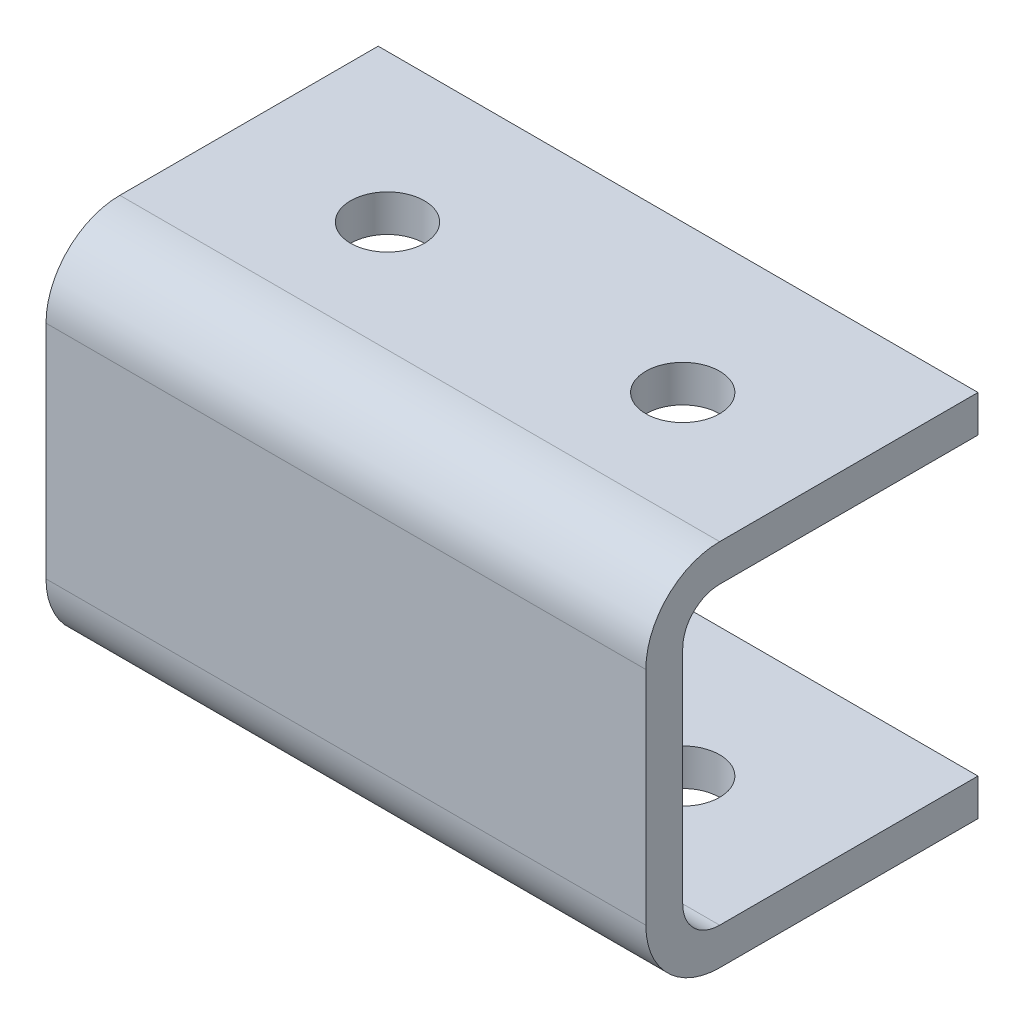
from build123d import *

# Parameters (mm, degrees)
SKETCH1_W          = 889
SKETCH1_H          = 31.75
EXTRUDE1_DEPTH     = 28.575
EXTRUDE2_REACH     = 891.702
SKETCH2_W          = 25.4
SKETCH2_H          = 25.4
HOLE1_D            = 6.35
HOLE1_DEPTH        = 3.175
LPATTERN1_COUNT    = 35
LPATTERN1_PITCH    = 25.4
HOLE2_D            = 9.652
LPATTERN2_COUNT    = 12
LPATTERN2_PITCH    = 25.4
HOLE3_D            = 9.652
HOLE4_D            = 9.652
LPATTERN3_COUNT    = 12
LPATTERN3_PITCH    = 25.4
HOLE5_D            = 3.175
HOLE6_D            = 6.35
LPATTERN4_COUNT    = 35
LPATTERN4_PITCH    = 25.4
FILLET1_R          = 3.175
FILLET2_R          = 3.175
FILLET3_R          = 6.35
FILLET4_R          = 6.35
SKETCH16_W         = 145.760071232
SKETCH16_H         = 71.504803879
CUT_EXTRUDE2_DEPTH = 75
SKETCH17_W         = 473.628565651
SKETCH17_H         = 66.908943447
CUT_EXTRUDE3_DEPTH = 186
SKETCH18_W         = 383.094897193
SKETCH18_H         = 93.915816603
CUT_EXTRUDE4_DEPTH = 186
SKETCH19_W         = 44.323760151
SKETCH19_H         = 53.749642994
CUT_EXTRUDE5_DEPTH = 186


with BuildPart() as part:
    # Sketch1 → Extrude1 (new body)
    with BuildSketch(Plane.XY.offset(3.175)):
        with Locations((428.480011997, 8.672957166)):
            Rectangle(SKETCH1_W, SKETCH1_H)
    extrude(amount=-EXTRUDE1_DEPTH)

    # Sketch2 → Extrude2 (cut, up to next)
    with BuildSketch(Plane.ZY.offset(16.019988003), mode=Mode.PRIVATE) as extrude2_sk1:
        with Locations((-12.7, 8.672957166)):
            Rectangle(SKETCH2_W, SKETCH2_H)
    extrude2_tool1 = extrude(extrude2_sk1.sketch, amount=-EXTRUDE2_REACH, mode=Mode.PRIVATE) & part.part
    add(extrude2_tool1.solids().sort_by_distance((-16.019988, 8.672957, -12.7))[0], mode=Mode.SUBTRACT)

    # Hole1
    with Locations(Plane(origin=(0, 24.547957166, 0), x_dir=(-1, 0, 0), z_dir=(0, 1, 0))):
        with Locations((3.319988003, -12.7)):
            hole1 = Hole(HOLE1_D / 2, depth=HOLE1_DEPTH)

    # LPattern1: Hole1 ×35
    with Locations(*[(i * LPATTERN1_PITCH, 0, 0) for i in range(1, LPATTERN1_COUNT)]):
        add(hole1, mode=Mode.SUBTRACT)

    # Hole2 (through all)
    with Locations(Plane.XY.offset(3.175)):
        with Locations((66.530011997, 10.577957166)):
            hole2 = Hole(HOLE2_D / 2)

    # LPattern2: Hole2 ×12, 8 skipped
    with Locations(*[(i * LPATTERN2_PITCH, 0, 0) for i in range(1, LPATTERN2_COUNT) if i not in (2, 3, 4, 5, 6, 7, 8, 9)]):
        add(hole2, mode=Mode.SUBTRACT)

    # Hole3 (through all)
    with Locations(Plane.XY.offset(3.175)):
        with Locations((428.480011997, 6.767957166)):
            Hole(HOLE3_D / 2)

    # Hole4 (through all)
    with Locations(Plane.XY.offset(3.175)):
        with Locations((511.030011997, 10.577957166)):
            hole4 = Hole(HOLE4_D / 2)

    # LPattern3: Hole4 ×12, 8 skipped
    with Locations(*[(i * LPATTERN3_PITCH, 0, 0) for i in range(1, LPATTERN3_COUNT) if i not in (2, 3, 4, 5, 6, 7, 8, 9)]):
        add(hole4, mode=Mode.SUBTRACT)

    # Hole5 (through all)
    with Locations(Plane.XY.offset(3.175)):
        with Locations((669.780011997, 8.672957166)):
            Hole(HOLE5_D / 2)

    # Hole6 (through all)
    with Locations(Plane(origin=(0, -4.027042834, 0), x_dir=(-1, 0, 0), z_dir=(0, 1, 0))):
        with Locations((3.319988003, -12.7)):
            hole6 = Hole(HOLE6_D / 2)

    # LPattern4: Hole6 ×35
    with Locations(*[(i * LPATTERN4_PITCH, 0, 0) for i in range(1, LPATTERN4_COUNT)]):
        add(hole6, mode=Mode.SUBTRACT)

    # Fillet1
    fillet1_edges = [part.edges().sort_by_distance(p)[0] for p in [
        (428.480011997, 21.372957166, 0),
    ]]
    fillet(fillet1_edges, radius=FILLET1_R)

    # Fillet2
    fillet2_edges = [part.edges().sort_by_distance(p)[0] for p in [
        (428.480011997, -4.027042834, 0),
    ]]
    fillet(fillet2_edges, radius=FILLET2_R)

    # Fillet3
    fillet3_edges = [part.edges().sort_by_distance(p)[0] for p in [
        (428.480011997, -7.202042834, 3.175),
    ]]
    fillet(fillet3_edges, radius=FILLET3_R)

    # Fillet4
    fillet4_edges = [part.edges().sort_by_distance(p)[0] for p in [
        (428.480011997, 24.547957166, 3.175),
    ]]
    fillet(fillet4_edges, radius=FILLET4_R)

    # Sketch16 → Cut-Extrude2 (cut)
    with BuildSketch(Plane(origin=(0, 24.547957166, 0), x_dir=(1, 0, 0), z_dir=(0, 1, 0))):
        with Locations((40.099976381, -10.352401939)):
            Rectangle(SKETCH16_W, SKETCH16_H)
    extrude(amount=-CUT_EXTRUDE2_DEPTH, mode=Mode.SUBTRACT)

    # Sketch17 → Cut-Extrude3 (cut)
    with BuildSketch(Plane(origin=(0, 24.547957166, 0), x_dir=(1, 0, 0), z_dir=(0, 1, 0))):
        with Locations((288.165729172, -8.054471723)):
            Rectangle(SKETCH17_W, SKETCH17_H)
    extrude(amount=-CUT_EXTRUDE3_DEPTH, mode=Mode.SUBTRACT)

    # Sketch18 → Cut-Extrude4 (cut)
    with BuildSketch(Plane(origin=(0, 24.547957166, 0), x_dir=(1, 0, 0), z_dir=(0, 1, 0))):
        with Locations((621.432563401, -21.557908301)):
            Rectangle(SKETCH18_W, SKETCH18_H)
    extrude(amount=-CUT_EXTRUDE4_DEPTH, mode=Mode.SUBTRACT)

    # Sketch19 → Cut-Extrude5 (cut)
    with BuildSketch(Plane(origin=(0, 24.547957166, 0), x_dir=(1, 0, 0), z_dir=(0, 1, 0))):
        with Locations((799.218131922, -1.474821497)):
            Rectangle(SKETCH19_W, SKETCH19_H)
    extrude(amount=-CUT_EXTRUDE5_DEPTH, mode=Mode.SUBTRACT)


solid = part.part
